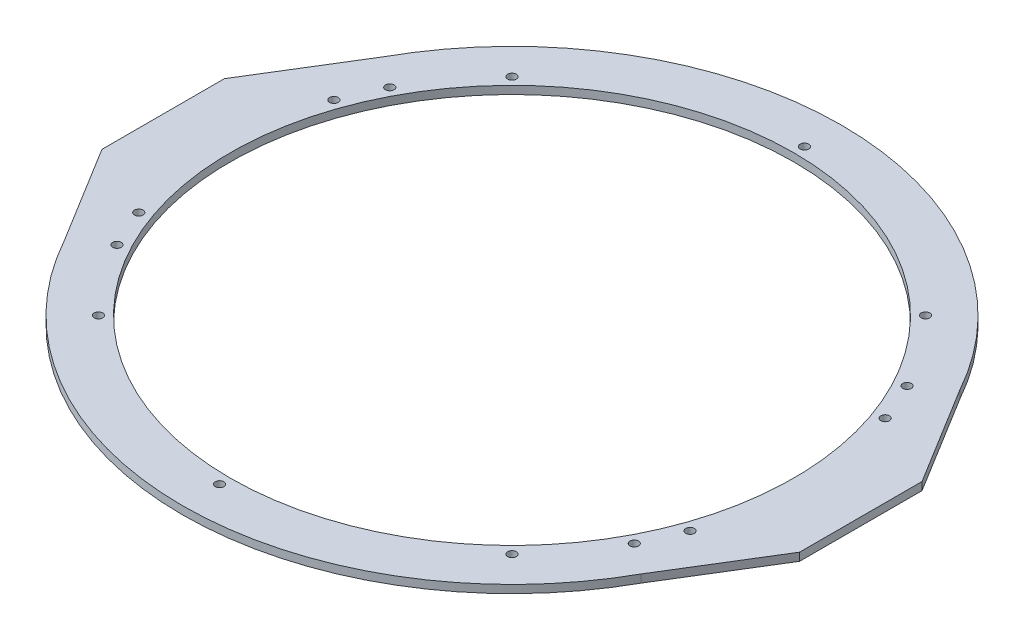
from build123d import *

# Parameters (mm, degrees)
SKETCH1_R               = 394.45
SKETCH1_R_2             = 337.3
BOSS_EXTRUDE1_DEPTH     = 9.525
SKETCH2_W               = 63.5
SKETCH2_H               = 206.256826312
CUT_EXTRUDE1_DEPTH      = 10.525
BOSS_EXTRUDE4_DEPTH     = 9.525
F_3_8_CLEARANCE_HOLE1_D = 10.31748
MIRROR3_COPY_1_D        = 10.31748
F_3_8_CLEARANCE_HOLE2_D = 10.31748
CIRPATTERN1_COUNT       = 8
CUT_EXTRUDE5_DEPTH      = 10.525
MIRROR9_COPY_1_DEPTH    = 10.525


with BuildPart() as part:
    # Sketch1 → Boss-Extrude1 (new body)
    with BuildSketch(Plane(origin=(0, 0, 0), x_dir=(1, 0, 0), z_dir=(0, 1, 0))):
        Circle(SKETCH1_R)
        Circle(SKETCH1_R_2, mode=Mode.SUBTRACT)
    extrude(amount=BOSS_EXTRUDE1_DEPTH)

    # Sketch2 → Cut-Extrude1 (cut, through all)
    with BuildSketch(Plane(origin=(0, 9.525, 0), x_dir=(1, 0, 0), z_dir=(0, 1, 0))):
        with Locations((-412.48, 0)):
            Rectangle(SKETCH2_W, SKETCH2_H)
    extrude(amount=-CUT_EXTRUDE1_DEPTH, mode=Mode.SUBTRACT)

    # Sketch5 → Boss-Extrude4 (add)
    with BuildSketch(Plane(origin=(0, 0, 0), x_dir=(1, 0, 0), z_dir=(0, 1, 0))):
        with BuildLine():
            Line((278.064904497, 190.921970677), (417.548677299, 190.921970677))
            Line((417.548677299, 190.921970677), (417.548677299, -190.921970677))
            Line((417.548677299, -190.921970677), (278.064904497, -190.921970677))
            ThreePointArc((278.064904497, -190.921970677), (337.3, 0), (278.064904497, 190.921970677))
        make_face()
    boss_extrude4 = extrude(amount=BOSS_EXTRUDE4_DEPTH)

    # Mirror1: Boss-Extrude4 across plane
    add(boss_extrude4.mirror(Plane(origin=(0, 0, 0), x_dir=(0, 0, 1), z_dir=(1, 0, 0))))

    # 3/8 Clearance Hole1 (through all)
    with Locations(Plane(origin=(0, 9.525, 0), x_dir=(-1, 0, 0), z_dir=(0, 1, 0))):
        with Locations((-329.955744274, 116.744193948), (-309.58033967, 163.278943192)):
            f_3_8_clearance_hole1 = Hole(F_3_8_CLEARANCE_HOLE1_D / 2)

    # Mirror2: 3/8 Clearance Hole1 across plane
    add(f_3_8_clearance_hole1.mirror(Plane(origin=(0, 0, 0), x_dir=(0, 0, 1), z_dir=(1, 0, 0))), mode=Mode.SUBTRACT)

    # Mirror3: 3/8 Clearance Hole1 across plane
    add(f_3_8_clearance_hole1.mirror(Plane.XY), mode=Mode.SUBTRACT)

    # Mirror3 copy 1 (through all)
    with Locations(Plane(origin=(0, 9.525, 0), x_dir=(1, 0, 0), z_dir=(0, 1, 0))):
        with Locations((-329.955744274, 116.744193948), (-309.58033967, 163.278943192)):
            Hole(MIRROR3_COPY_1_D / 2)

    # 3/8 Clearance Hole2 (through all)
    with Locations(Plane(origin=(0, 9.525, 0), x_dir=(1, 0, 0), z_dir=(0, 1, 0))):
        with Locations((247.487373415, -247.487373415)):
            f_3_8_clearance_hole2 = Hole(F_3_8_CLEARANCE_HOLE2_D / 2)

    # CirPattern1: 3/8 Clearance Hole2 ×8 about axis, 2 skipped
    cirpattern1_axis = Axis((0, 0, 0), (0, 1, 0))
    add([f_3_8_clearance_hole2.rotate(cirpattern1_axis, i * 360 / CIRPATTERN1_COUNT) for i in range(1, CIRPATTERN1_COUNT) if i not in (1, 5)], mode=Mode.SUBTRACT)

    # Sketch12 → Cut-Extrude5 (cut, through all)
    with BuildSketch(Plane(origin=(0, 0, 0), x_dir=(1, 0, 0), z_dir=(0, 1, 0))):
        Polygon((-417.548677299, 190.921970677), (-417.548677299, 73.2544087), (-345.166052231, 190.921970677), align=None)
    cut_extrude5 = extrude(amount=CUT_EXTRUDE5_DEPTH, mode=Mode.SUBTRACT)

    # Mirror8: Cut-Extrude5 across plane
    add(cut_extrude5.mirror(Plane.XY), mode=Mode.SUBTRACT)

    # Mirror9: Cut-Extrude5 across plane
    add(cut_extrude5.mirror(Plane(origin=(0, 0, 0), x_dir=(0, 0, 1), z_dir=(1, 0, 0))), mode=Mode.SUBTRACT)

    # Mirror9 copy 1 sketch → Mirror9 copy 1 (cut, through all)
    with BuildSketch(Plane(origin=(0, 0, 0), x_dir=(-1, 0, 0), z_dir=(0, 1, 0))):
        Polygon((-417.548677299, 190.921970677), (-417.548677299, 73.2544087), (-345.166052231, 190.921970677), align=None)
    extrude(amount=MIRROR9_COPY_1_DEPTH, mode=Mode.SUBTRACT)


solid = part.part
